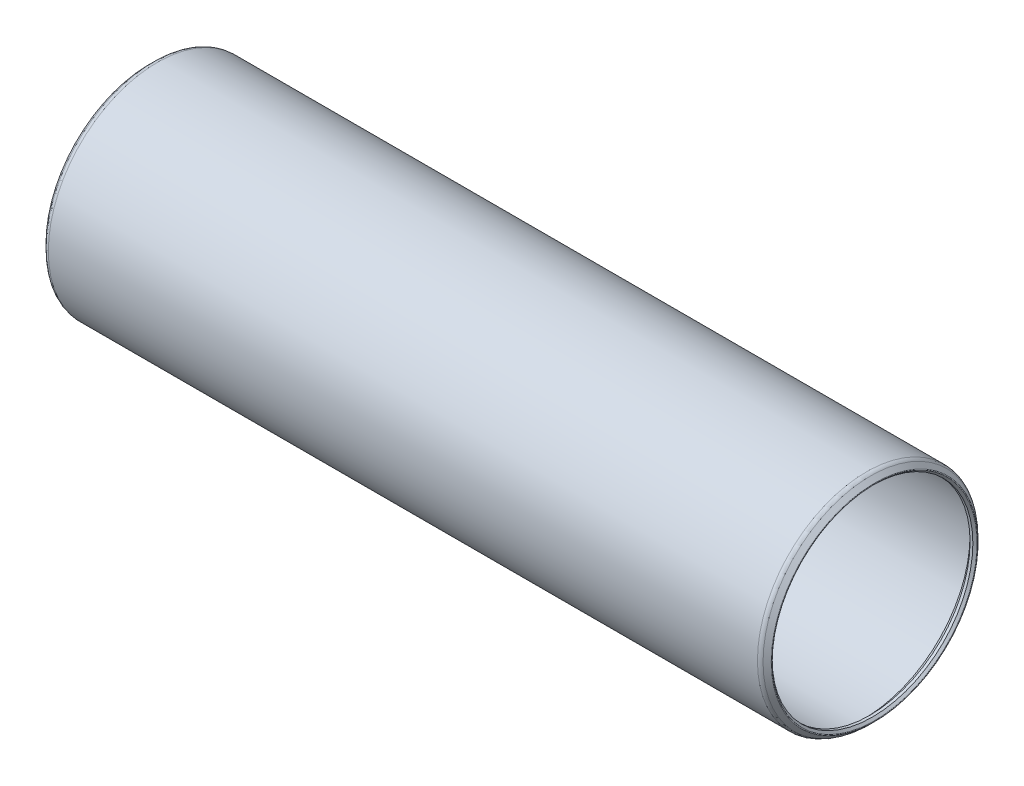
from build123d import *


with BuildPart() as part:
    # Sketch1 → Revolve1 (revolve)
    with BuildSketch(Plane.XY):
        with BuildLine():
            Line((-0.882617928, 18.554667928), (-0.508, 18.18005))
            Line((-0.508, 18.18005), (0, 18.18005))
            Line((0, 18.18005), (1.016, 19.19605))
            Line((1.016, 19.19605), (128.5875, 19.19605))
            Line((128.5875, 19.19605), (129.6035, 18.18005))
            Line((129.6035, 18.18005), (130.1115, 18.18005))
            Line((130.1115, 18.18005), (130.486117928, 18.554667928))
            ThreePointArc((130.486117928, 18.554667928), (130.523315367, 18.64447049), (130.486117928, 18.734273051))
            Line((130.486117928, 18.734273051), (129.75042049, 19.46997049))
            ThreePointArc((129.75042049, 19.46997049), (129.420806367, 19.690211605), (129.032, 19.76755))
            Line((129.032, 19.76755), (0.5715, 19.76755))
            ThreePointArc((0.5715, 19.76755), (0.182693633, 19.690211605), (-0.14692049, 19.46997049))
            Line((-0.14692049, 19.46997049), (-0.882617928, 18.734273051))
            ThreePointArc((-0.882617928, 18.734273051), (-0.919815367, 18.64447049), (-0.882617928, 18.554667928))
        make_face()
    revolve(axis=Axis((129.6035, 0, 0), (-1, 0, 0)))


solid = part.part
